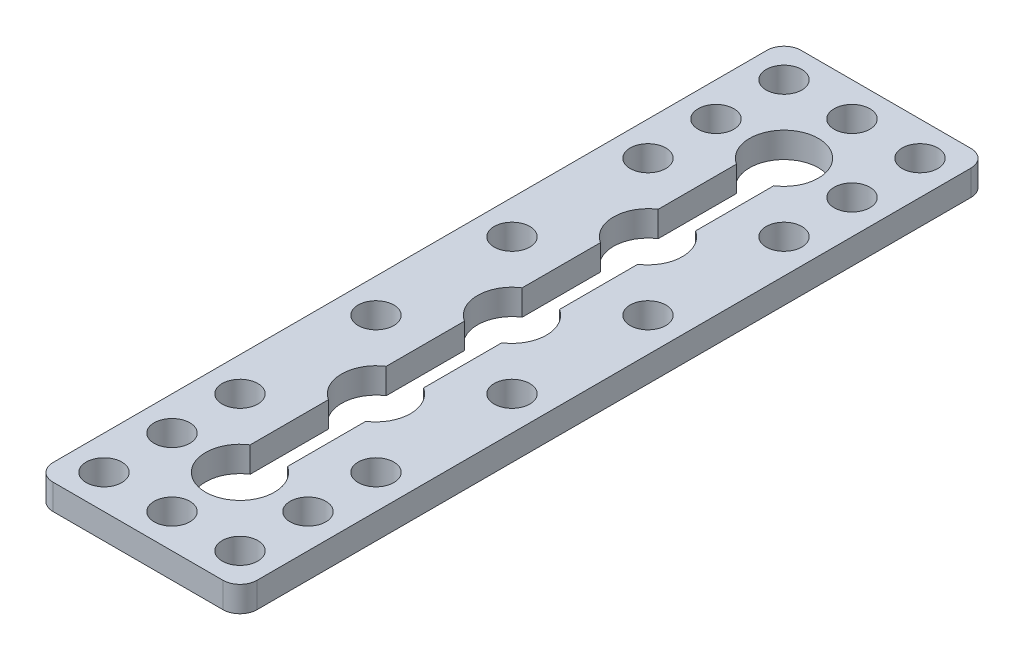
from build123d import *

# Parameters (mm, degrees)
SKETCH1_W           = 24
SKETCH1_H           = 88
BOSS_EXTRUDE1_DEPTH = 3
SKETCH2_R           = 2.1
CUT_EXTRUDE1_DEPTH  = 4
SKETCH3_R           = 4.05
CUT_EXTRUDE2_DEPTH  = 4
LPATTERN1_COUNT     = 5
LPATTERN1_PITCH     = 16
SKETCH4_W           = 4.4
SKETCH4_H           = 64
CUT_EXTRUDE3_DEPTH  = 4
FILLET1_R           = 2


with BuildPart() as part:
    # Sketch1 → Boss-Extrude1 (new body)
    with BuildSketch(Plane(origin=(0, 0, 0), x_dir=(1, 0, 0), z_dir=(0, 1, 0))):
        with Locations((12, 44)):
            Rectangle(SKETCH1_W, SKETCH1_H)
    extrude(amount=BOSS_EXTRUDE1_DEPTH)

    # Sketch2 → Cut-Extrude1 (cut, through all)
    with BuildSketch(Plane(origin=(0, 3, 0), x_dir=(1, 0, 0), z_dir=(0, 1, 0))):
        with Locations((12, 84)):
            Circle(SKETCH2_R)
        with Locations((4, 84)):
            Circle(SKETCH2_R)
        with Locations((4, 76)):
            Circle(SKETCH2_R)
        with Locations((4, 68)):
            Circle(SKETCH2_R)
        with Locations((4, 52)):
            Circle(SKETCH2_R)
        with Locations((20, 52)):
            Circle(SKETCH2_R)
        with Locations((20, 68)):
            Circle(SKETCH2_R)
        with Locations((20, 76)):
            Circle(SKETCH2_R)
        with Locations((20, 84)):
            Circle(SKETCH2_R)
        with Locations((20, 4)):
            Circle(SKETCH2_R)
        with Locations((20, 12)):
            Circle(SKETCH2_R)
        with Locations((20, 20)):
            Circle(SKETCH2_R)
        with Locations((20, 36)):
            Circle(SKETCH2_R)
        with Locations((4, 36)):
            Circle(SKETCH2_R)
        with Locations((4, 20)):
            Circle(SKETCH2_R)
        with Locations((4, 12)):
            Circle(SKETCH2_R)
        with Locations((4, 4)):
            Circle(SKETCH2_R)
        with Locations((12, 4)):
            Circle(SKETCH2_R)
    extrude(amount=-CUT_EXTRUDE1_DEPTH, mode=Mode.SUBTRACT)

    # Sketch3 → Cut-Extrude2 (cut, through all)
    with BuildSketch(Plane(origin=(0, 3, 0), x_dir=(1, 0, 0), z_dir=(0, 1, 0))):
        with Locations((12, 76)):
            Circle(SKETCH3_R)
    cut_extrude2 = extrude(amount=-CUT_EXTRUDE2_DEPTH, mode=Mode.SUBTRACT)

    # LPattern1: Cut-Extrude2 ×5
    with Locations(*[(0, 0, i * LPATTERN1_PITCH) for i in range(1, LPATTERN1_COUNT)]):
        add(cut_extrude2, mode=Mode.SUBTRACT)

    # Sketch4 → Cut-Extrude3 (cut, through all)
    with BuildSketch(Plane(origin=(0, 3, 0), x_dir=(1, 0, 0), z_dir=(0, 1, 0))):
        with Locations((12, 44)):
            Rectangle(SKETCH4_W, SKETCH4_H)
    extrude(amount=-CUT_EXTRUDE3_DEPTH, mode=Mode.SUBTRACT)

    # Fillet1
    fillet1_edges = [part.edges().sort_by_distance(p)[0] for p in [
        (0, 1.5, -88),
        (24, 1.5, -88),
        (24, 1.5, 0),
        (0, 1.5, 0),
    ]]
    fillet(fillet1_edges, radius=FILLET1_R)


solid = part.part
